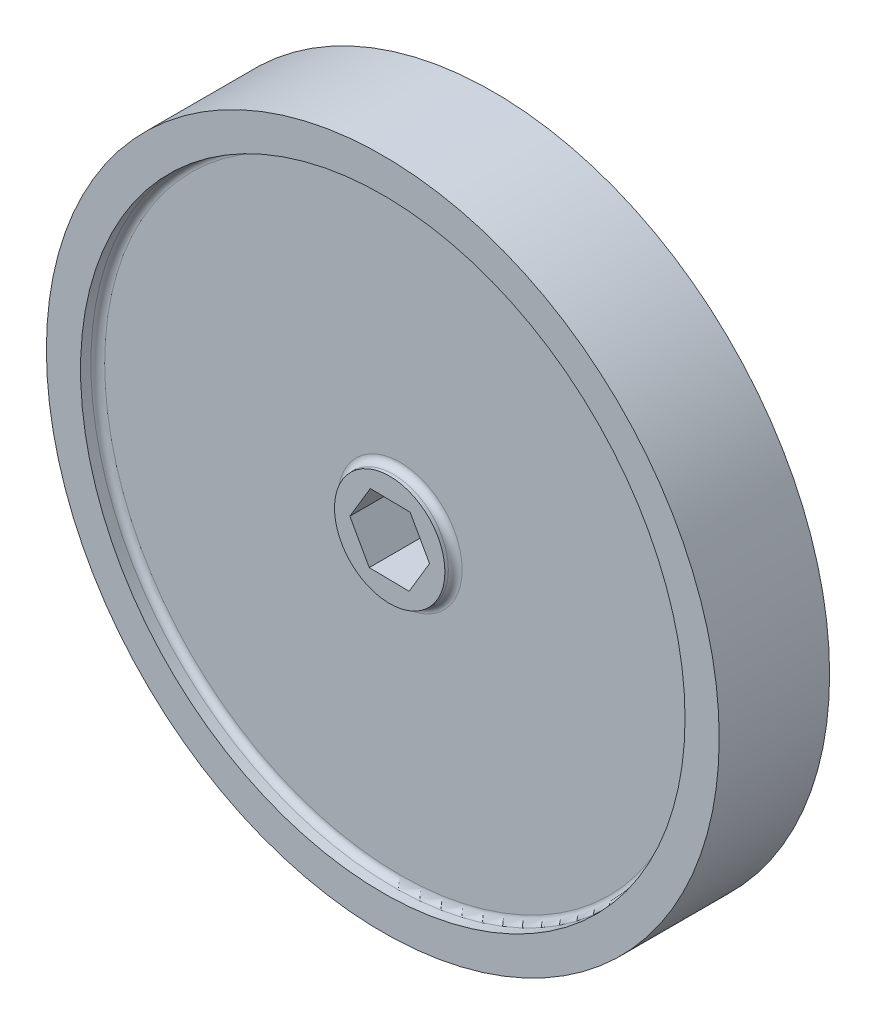
from build123d import *

# Parameters (mm, degrees)
SKETCH1_R           = 61.9125
BOSS_EXTRUDE1_DEPTH = 20.32
SKETCH2_R           = 55.626
SKETCH2_R_2         = 10.16
CUT_EXTRUDE1_DEPTH  = 3.175
SKETCH3_R           = 55.626
SKETCH3_R_2         = 10.16
CUT_EXTRUDE2_DEPTH  = 3.175
SKETCH4_R           = 10.16
CUT_EXTRUDE3_DEPTH  = 1.27
SKETCH7_R           = 10.16
CUT_EXTRUDE5_DEPTH  = 1.27
FILLET1_R           = 1.27


with BuildPart() as part:
    # Sketch1 → Boss-Extrude1 (new body)
    with BuildSketch(Plane.XY):
        Circle(SKETCH1_R)
        Polygon((3.569234353, -6.4049902), (7.331501401, -0.111447478), (3.762267048, 6.293542722), (-3.569234353, 6.4049902), (-7.331501401, 0.111447478), (-3.762267048, -6.293542722), align=None, mode=Mode.SUBTRACT)
    extrude(amount=BOSS_EXTRUDE1_DEPTH)

    # Sketch2 → Cut-Extrude1 (cut)
    with BuildSketch(Plane.XY.offset(20.32)):
        Circle(SKETCH2_R)
        Circle(SKETCH2_R_2, mode=Mode.SUBTRACT)
    extrude(amount=-CUT_EXTRUDE1_DEPTH, mode=Mode.SUBTRACT)

    # Sketch3 → Cut-Extrude2 (cut)
    with BuildSketch(Plane(origin=(0, 0, 0), x_dir=(-1, 0, 0), z_dir=(0, 0, -1))):
        Circle(SKETCH3_R)
        Circle(SKETCH3_R_2, mode=Mode.SUBTRACT)
    extrude(amount=-CUT_EXTRUDE2_DEPTH, mode=Mode.SUBTRACT)

    # Sketch4 → Cut-Extrude3 (cut)
    with BuildSketch(Plane(origin=(0, 0, 0), x_dir=(-1, 0, 0), z_dir=(0, 0, -1))):
        Circle(SKETCH4_R)
    extrude(amount=-CUT_EXTRUDE3_DEPTH, mode=Mode.SUBTRACT)

    # Sketch7 → Cut-Extrude5 (cut)
    with BuildSketch(Plane.XY.offset(20.32)):
        Circle(SKETCH7_R)
    extrude(amount=-CUT_EXTRUDE5_DEPTH, mode=Mode.SUBTRACT)

    # Fillet1
    fillet1_edges = [part.edges().sort_by_distance(p)[0] for p in [
        (-55.626, 0, 17.145),
        (-10.16, 0, 17.145),
        (55.626, 0, 3.175),
        (10.16, 0, 3.175),
    ]]
    fillet(fillet1_edges, radius=FILLET1_R)


solid = part.part
